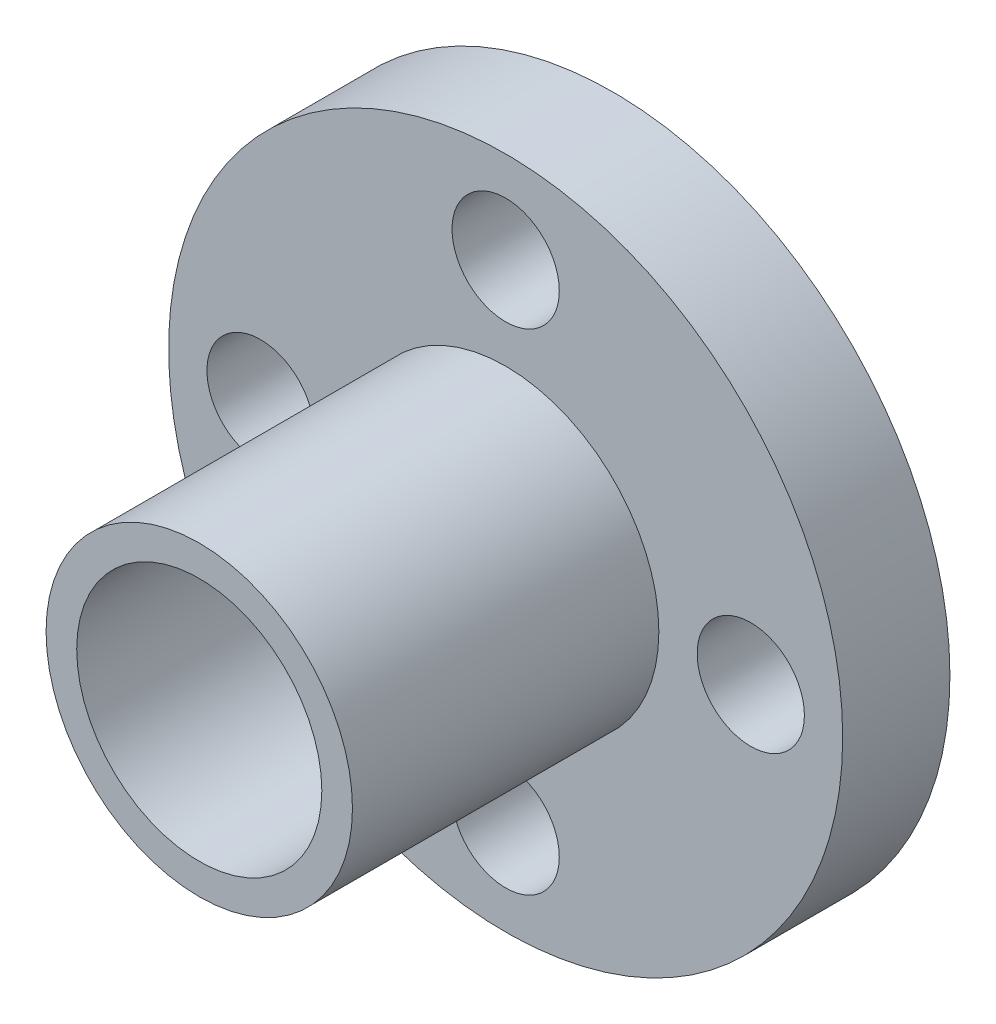
from build123d import *

# Parameters (mm, degrees)
SKETCH1_R           = 5
BOSS_EXTRUDE1_DEPTH = 1.5
SKETCH2_R           = 11
BOSS_EXTRUDE2_DEPTH = 3.5
SKETCH3_R           = 5
BOSS_EXTRUDE3_DEPTH = 10
SKETCH4_R           = 1.75
CUT_EXTRUDE1_DEPTH  = 4
SKETCH5_R           = 4
CUT_EXTRUDE2_DEPTH  = 15


with BuildPart() as part:
    # Sketch1 → Boss-Extrude1 (new body)
    with BuildSketch(Plane.XY):
        Circle(SKETCH1_R)
    extrude(amount=BOSS_EXTRUDE1_DEPTH)

    # Sketch2 → Boss-Extrude2 (add)
    with BuildSketch(Plane.XY.offset(1.5)):
        Circle(SKETCH2_R)
    extrude(amount=BOSS_EXTRUDE2_DEPTH)

    # Sketch3 → Boss-Extrude3 (add)
    with BuildSketch(Plane.XY.offset(5)):
        Circle(SKETCH3_R)
    extrude(amount=BOSS_EXTRUDE3_DEPTH)

    # Sketch4 → Cut-Extrude1 (cut)
    with BuildSketch(Plane.XY.offset(5)):
        with Locations((0, 8)):
            Circle(SKETCH4_R)
        with Locations((0, -8)):
            Circle(SKETCH4_R)
        with Locations((8, 0)):
            Circle(SKETCH4_R)
        with Locations((-8, 0)):
            Circle(SKETCH4_R)
    extrude(amount=-CUT_EXTRUDE1_DEPTH, mode=Mode.SUBTRACT)

    # Sketch5 → Cut-Extrude2 (cut)
    with BuildSketch(Plane.XY.offset(15)):
        Circle(SKETCH5_R)
    extrude(amount=-CUT_EXTRUDE2_DEPTH, mode=Mode.SUBTRACT)


solid = part.part
